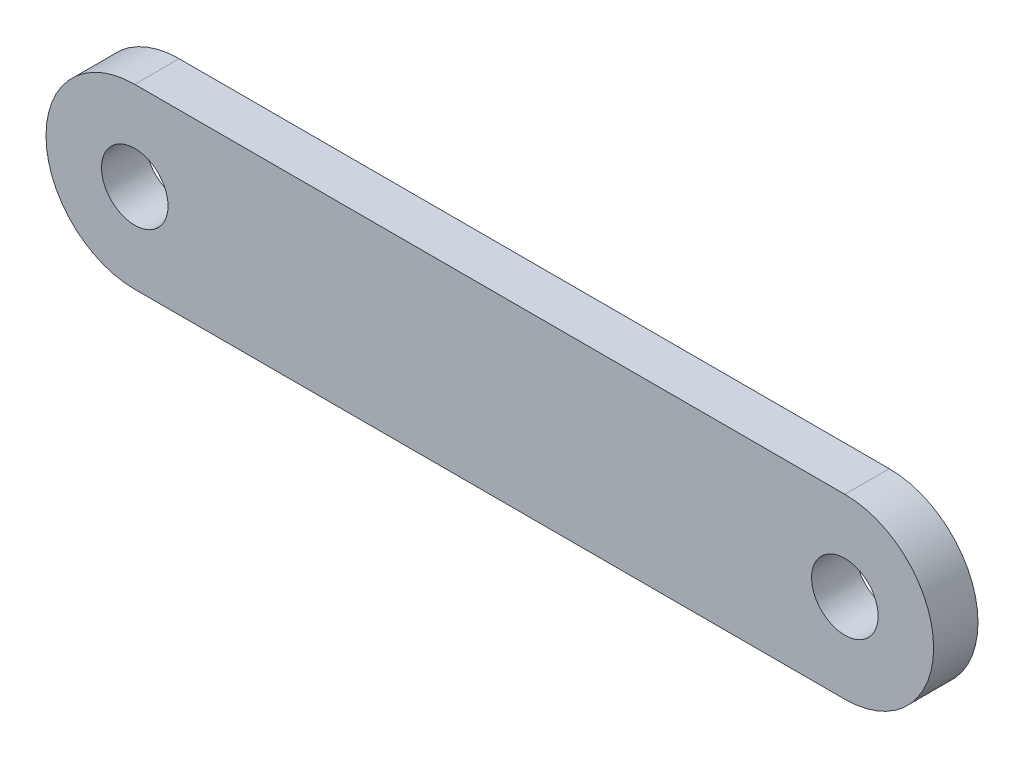
from build123d import *

# Parameters (mm, degrees)
SKETCH1_R           = 4.7625
BOSS_EXTRUDE1_DEPTH = 6.35


with BuildPart() as part:
    # Sketch1 → Boss-Extrude1 (new body)
    with BuildSketch(Plane.XY):
        with BuildLine():
            Line((-50.8, 12.7), (50.8, 12.7))
            ThreePointArc((50.8, 12.7), (63.5, 0), (50.8, -12.7))
            Line((50.8, -12.7), (-50.8, -12.7))
            ThreePointArc((-50.8, -12.7), (-63.5, 0), (-50.8, 12.7))
        make_face()
        with Locations((-50.8, 0)):
            Circle(SKETCH1_R, mode=Mode.SUBTRACT)
        with Locations((50.8, 0)):
            Circle(SKETCH1_R, mode=Mode.SUBTRACT)
    extrude(amount=BOSS_EXTRUDE1_DEPTH)


solid = part.part
